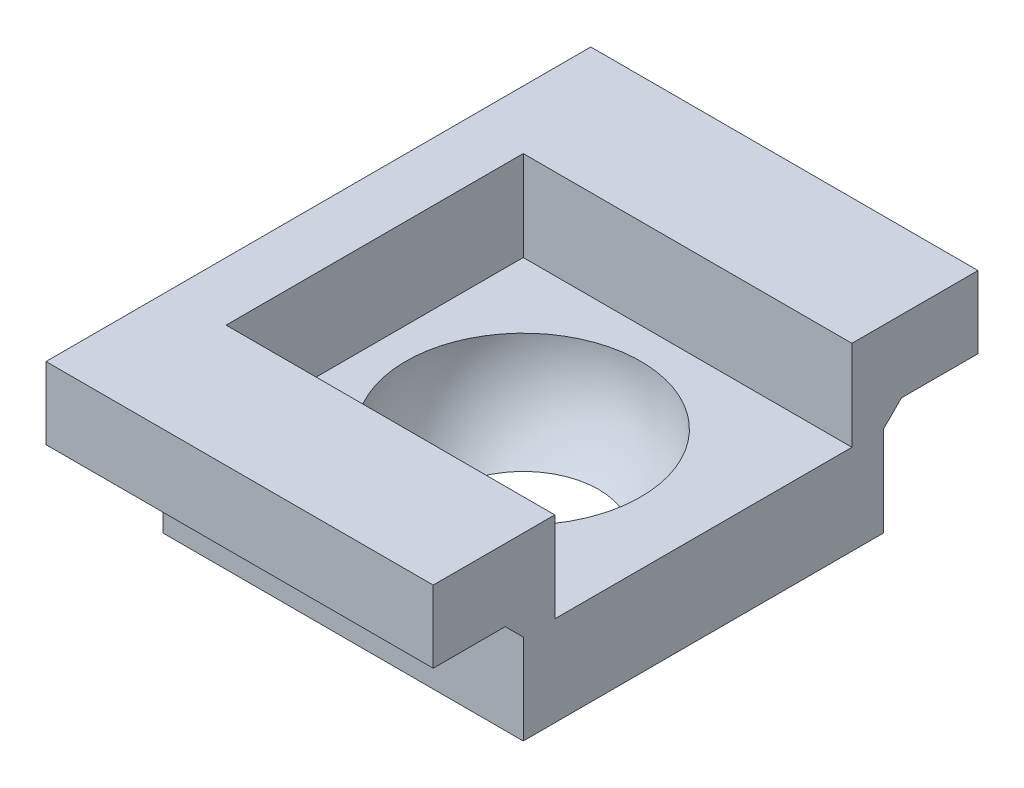
from build123d import *

# Parameters (mm, degrees)
SKETCH1_W           = 4
SKETCH1_H           = 4
BOSS_EXTRUDE1_DEPTH = 2
SKETCH3_W           = 6.995739113
SKETCH3_H           = 4.795831112
CUT_EXTRUDE1_DEPTH  = 1
BOSS_EXTRUDE2_DEPTH = 1
SKETCH5_W           = 4
SKETCH5_H           = 0.8
BOSS_EXTRUDE3_DEPTH = 1
SKETCH6_W           = 4
SKETCH6_H           = 0.8
BOSS_EXTRUDE4_DEPTH = 1
SKETCH8_W           = 4
SKETCH8_H           = 0.05
CUT_EXTRUDE2_DEPTH  = 0.2
SKETCH9_W           = 6.05
SKETCH9_H           = 0.8
BOSS_EXTRUDE6_DEPTH = 0.3
SKETCH10_W          = 4.051772222
SKETCH10_H          = 3.3
CUT_EXTRUDE3_DEPTH  = 1
BOSS_EXTRUDE7_DEPTH = 4
BOSS_EXTRUDE8_DEPTH = 4


with BuildPart() as part:
    # Sketch1 → Boss-Extrude1 (new body)
    with BuildSketch(Plane(origin=(0, 0, 0), x_dir=(1, 0, 0), z_dir=(0, 1, 0))):
        with Locations((-0.305984445, 0.016020496)):
            Rectangle(SKETCH1_W, SKETCH1_H)
    extrude(amount=BOSS_EXTRUDE1_DEPTH)

    # Sketch2 → Cut-Revolve1 (revolve, cut)
    with BuildSketch(Plane(origin=(0, 2, 0), x_dir=(1, 0, 0), z_dir=(0, 1, 0))):
        with BuildLine():
            Line((-0.305984445, -1.288979504), (-0.305984445, 1.321020496))
            ThreePointArc((-0.305984445, 1.321020496), (-1.610984445, 0.016020496), (-0.305984445, -1.288979504))
        make_face()
    revolve(axis=Axis((-0.305984445, 2, 1.288979504), (0, 0, -1)), mode=Mode.SUBTRACT)

    # Sketch3 → Cut-Extrude1 (cut)
    with BuildSketch(Plane.XZ):
        with Locations((-1.219435612, 0.226207457)):
            Rectangle(SKETCH3_W, SKETCH3_H)
    extrude(amount=-CUT_EXTRUDE1_DEPTH, mode=Mode.SUBTRACT)

    # Sketch4 → Boss-Extrude2 (add)
    with BuildSketch(Plane(origin=(0, 2, 0), x_dir=(1, 0, 0), z_dir=(0, 1, 0))):
        Polygon((-1.905984445, -1.583979504), (1.515020657, -1.583979504), (1.694015555, -1.583979504), (1.694015555, -1.983979504), (-2.305984445, -1.983979504), (-2.305984445, 2.066020496), (1.694015555, 2.066020496), (1.694015555, 1.616020496), (1.515020657, 1.616020496), (-1.905984445, 1.616020496), align=None)
    extrude(amount=BOSS_EXTRUDE2_DEPTH)

    # Sketch5 → Boss-Extrude3 (add)
    with BuildSketch(Plane.XY.offset(1.983979504)):
        with Locations((-0.305984445, 2.6)):
            Rectangle(SKETCH5_W, SKETCH5_H)
    extrude(amount=BOSS_EXTRUDE3_DEPTH)

    # Sketch6 → Boss-Extrude4 (add)
    with BuildSketch(Plane(origin=(0, 0, -2.066020496), x_dir=(-1, 0, 0), z_dir=(0, 0, -1))):
        with Locations((0.305984445, 2.6)):
            Rectangle(SKETCH6_W, SKETCH6_H)
    extrude(amount=BOSS_EXTRUDE4_DEPTH)

    # Sketch8 → Cut-Extrude2 (cut)
    with BuildSketch(Plane.XZ.offset(-2)):
        with Locations((-0.305984445, -2.041020496)):
            Rectangle(SKETCH8_W, SKETCH8_H)
    extrude(amount=-CUT_EXTRUDE2_DEPTH, mode=Mode.SUBTRACT)

    # Sketch9 → Boss-Extrude6 (add)
    with BuildSketch(Plane.ZY.offset(2.305984445)):
        with Locations((-0.041020496, 2.6)):
            Rectangle(SKETCH9_W, SKETCH9_H)
    extrude(amount=BOSS_EXTRUDE6_DEPTH)

    # Sketch10 → Cut-Extrude3 (cut)
    with BuildSketch(Plane(origin=(0, 3, 0), x_dir=(1, 0, 0), z_dir=(0, 1, 0))):
        with Locations((0.069901666, 0.016020496)):
            Rectangle(SKETCH10_W, SKETCH10_H)
    extrude(amount=-CUT_EXTRUDE3_DEPTH, mode=Mode.SUBTRACT)

    # Sketch11 → Boss-Extrude7 (add)
    with BuildSketch(Plane(origin=(1.694015555, 0, 0), x_dir=(0, 0, -1), z_dir=(1, 0, 0))):
        Polygon((-1.983979504, 2), (-2.183979504, 2.2), (-1.983979504, 2.2), align=None)
    extrude(amount=-BOSS_EXTRUDE7_DEPTH)

    # Sketch12 → Boss-Extrude8 (add)
    with BuildSketch(Plane(origin=(1.694015555, 0, 0), x_dir=(0, 0, -1), z_dir=(1, 0, 0))):
        Polygon((2.016020496, 2.2), (2.016020496, 2), (2.216020496, 2.2), align=None)
    extrude(amount=-BOSS_EXTRUDE8_DEPTH)


solid = part.part
